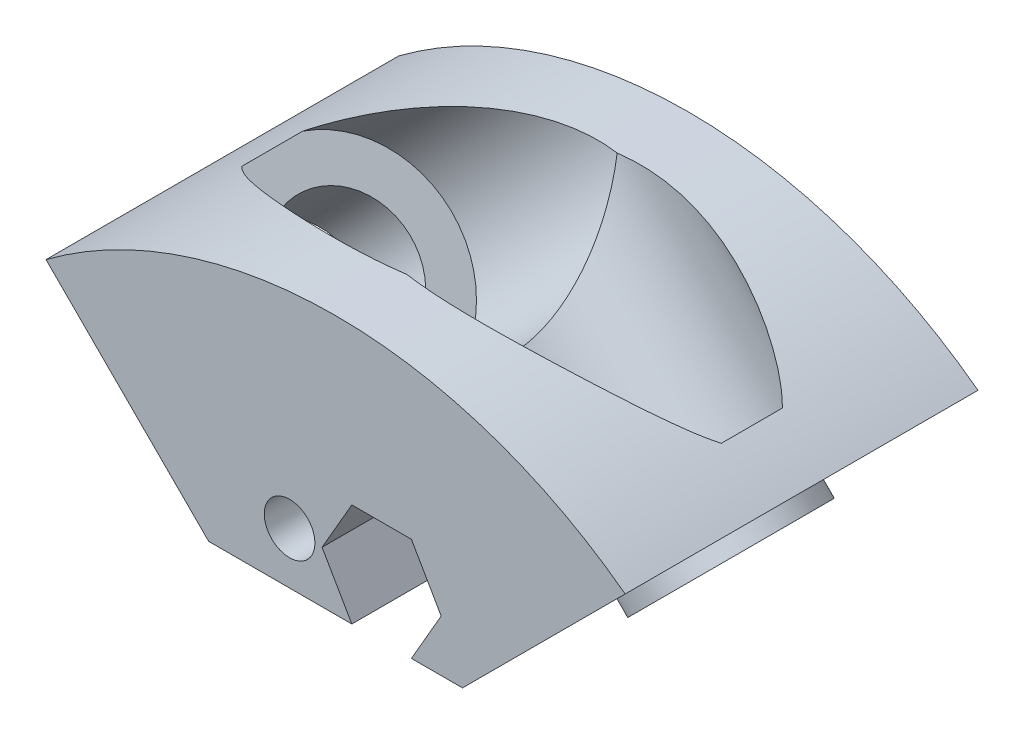
from build123d import *

# Parameters (mm, degrees)
BOSS_EXTRUDE1_DEPTH     = 11.5
SKETCH7_R               = 4.300000000000005
CUT_EXTRUDE5_DEPTH      = 38.71173316494823
CUT_EXTRUDE6_START      = -3.8
SKETCH7_3_R             = 7.000000000000001
SKETCH7_3_R_2           = 4.300000000000005
CUT_EXTRUDE6_DEPTH      = 34.911733336115425
CUT_EXTRUDE7_DEPTH      = 39.5017533676133
CUT_EXTRUDE7_DEPTH_BACK = 39.5017533676133
SKETCH8_R               = 1.6499999999999981
SKETCH8_R_2             = 1.6499999999999992
CUT_EXTRUDE8_START      = -5
SKETCH8_3_R             = 1.6499999999999981
CUT_EXTRUDE8_DEPTH      = 34.5017533676133
CUT_EXTRUDE9_START      = 5
SKETCH8_4_R             = 1.6499999999999992
CUT_EXTRUDE9_DEPTH      = 34.5017533676133


with BuildPart() as part:
    # Sketch4 → Boss-Extrude1 (new, symmetric)
    with BuildSketch(Plane.XY):
        with BuildLine():
            ThreePointArc((18.879751057680817, 25.243712088359754), (-4.174e-14, 31.52284885602822), (-18.879751057680878, 25.243712088359697))
            Line((-18.879751057680878, 25.243712088359697), (-17.465537495307785, 23.829498525986608))
            Line((-17.465537495307785, 23.829498525986608), (-16.617009357883926, 22.980970388562753))
            Line((-16.617009357883926, 22.980970388562753), (-13.57645019878176, 19.940411229460604))
            Line((-13.57645019878176, 19.940411229460604), (-9.687362902255748, 16.051323932934608))
            Line((-9.687362902255748, 16.051323932934608), (-8.27314933988264, 14.637110370561505))
            Line((-8.27314933988264, 14.637110370561505), (8.273149339882583, 14.637110370561558))
            Line((8.273149339882583, 14.637110370561558), (9.687362902255678, 16.05132393293465))
            Line((9.687362902255678, 16.05132393293465), (13.576450198781696, 19.940411229460654))
            Line((13.576450198781696, 19.940411229460654), (16.617009357883855, 22.980970388562802))
            Line((16.617009357883855, 22.980970388562802), (17.465537495307714, 23.82949852598666))
            Line((17.465537495307714, 23.82949852598666), (18.879751057680814, 25.243712088359754))
        make_face()
    extrude(amount=BOSS_EXTRUDE1_DEPTH, both=True)

    # Sketch4_3 → Revolve1 (revolve)
    with BuildSketch(Plane.XY):
        Polygon((-16.617009357883926, 22.980970388562753), (-17.465537495307785, 23.829498525986608), (-18.172644276494324, 23.12239174480006), (-17.32411613907047, 22.273863607376207), align=None)
    revolve1 = revolve(axis=Axis((-14.283556979968314, 19.23330444827406, 0), (0.7071067811865528, 0.7071067811865424, 0)))

    # Sketch7 → Cut-Extrude5 (cut, symmetric)
    with BuildSketch(Plane(origin=(3.1819805153394545, 3.1819805153394696, 0), x_dir=(0, 0, 1), z_dir=(-0.707106781186546, -0.707106781186549, 0))):
        with Locations((0, 23.700000000000003)):
            Circle(SKETCH7_R)
    cut_extrude5 = extrude(amount=CUT_EXTRUDE5_DEPTH, both=True, mode=Mode.SUBTRACT)

    # Sketch7_3 → Cut-Extrude6 (cut, through all)
    with BuildSketch(Plane(origin=(3.1819805153394545, 3.1819805153394696, 0), x_dir=(0, 0, 1), z_dir=(-0.707106781186546, -0.707106781186549, 0)).offset(CUT_EXTRUDE6_START)):
        with Locations((0, 23.700000000000003)):
            Circle(SKETCH7_3_R)
        with Locations((0, 23.700000000000003)):
            Circle(SKETCH7_3_R_2, mode=Mode.SUBTRACT)
    cut_extrude6 = extrude(amount=-CUT_EXTRUDE6_DEPTH, mode=Mode.SUBTRACT)

    # Mirror2: Revolve1, Cut-Extrude5, Cut-Extrude6 across plane
    add(revolve1.mirror(Plane(origin=(0, 0, 0), x_dir=(0, 0, 1), z_dir=(1, 0, 0))))
    add(cut_extrude5.mirror(Plane(origin=(0, 0, 0), x_dir=(0, 0, 1), z_dir=(1, 0, 0))), mode=Mode.SUBTRACT)
    add(cut_extrude6.mirror(Plane(origin=(0, 0, 0), x_dir=(0, 0, 1), z_dir=(1, 0, 0))), mode=Mode.SUBTRACT)

    # Sketch8 → Cut-Extrude7 (cut, two sides: drawn at the far end of the back side and taken through both)
    with BuildSketch(Plane.XY.offset(-CUT_EXTRUDE7_DEPTH_BACK)):
        with Locations((-3, 18)):
            Circle(SKETCH8_R)
        with Locations((3, 18)):
            Circle(SKETCH8_R_2)
    extrude(amount=CUT_EXTRUDE7_DEPTH + CUT_EXTRUDE7_DEPTH_BACK, mode=Mode.SUBTRACT)

    # Sketch8_3 → Cut-Extrude8 (cut, through all)
    with BuildSketch(Plane.XY.offset(CUT_EXTRUDE8_START)):
        Polygon((-4.941565232811313, 21.362889629438488), (-6.8831304656226235, 18), (-4.941565232811313, 14.63711037056151), (-1.0584347671886887, 14.63711037056151), (0.8831304656226224, 18), (-1.058434767188688, 21.362889629438488), align=None)
        with Locations((-3, 18)):
            Circle(SKETCH8_3_R, mode=Mode.SUBTRACT)
    extrude(amount=-CUT_EXTRUDE8_DEPTH, mode=Mode.SUBTRACT)

    # Sketch8_4 → Cut-Extrude9 (cut, through all)
    with BuildSketch(Plane.XY.offset(CUT_EXTRUDE9_START)):
        Polygon((-0.8831304656226175, 18.000000000000004), (1.0584347671886944, 14.63711037056151), (4.941565232811313, 14.63711037056151), (6.883130465622625, 18), (4.941565232811314, 21.362889629438488), (1.0584347671886913, 21.362889629438488), align=None)
        with Locations((3, 18)):
            Circle(SKETCH8_4_R, mode=Mode.SUBTRACT)
    extrude(amount=CUT_EXTRUDE9_DEPTH, mode=Mode.SUBTRACT)


solid = part.part
